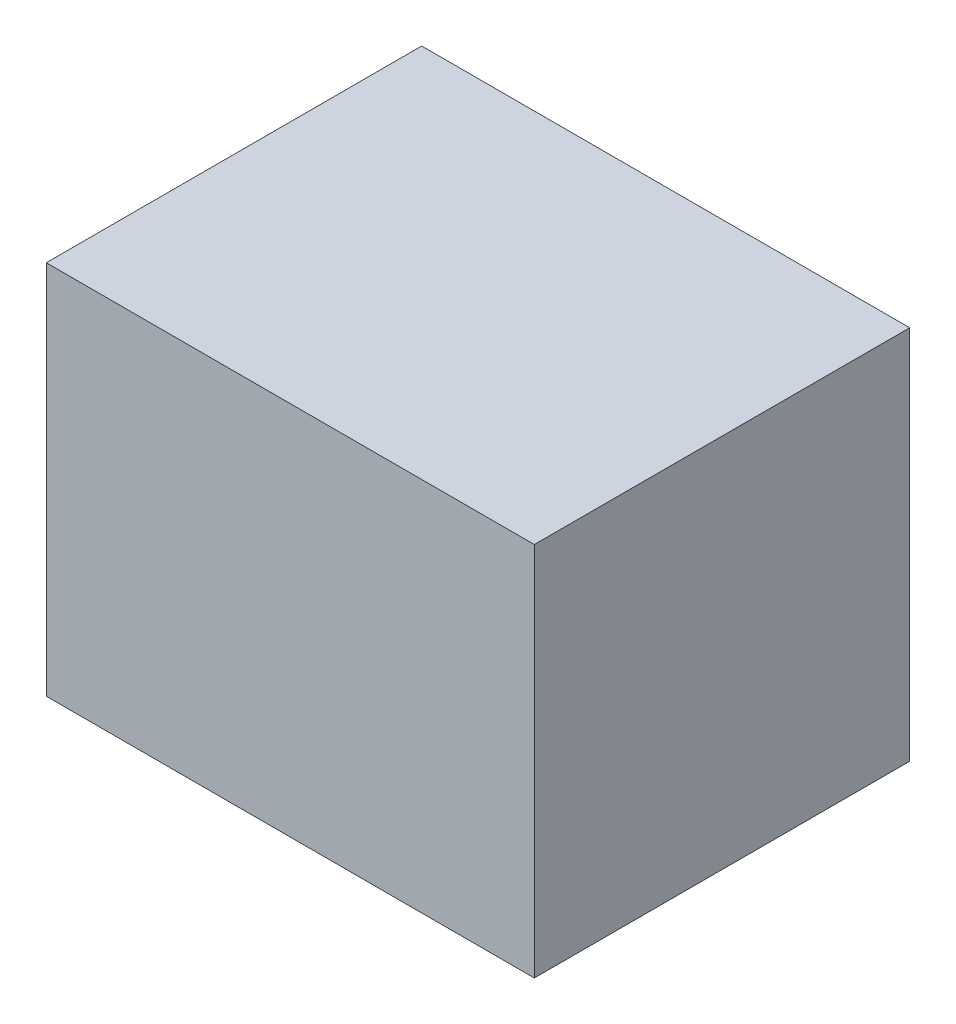
from build123d import *

# Parameters (mm, degrees)
SKETCH1_W           = 650
SKETCH1_H           = 500
BOSS_EXTRUDE1_DEPTH = 500


with BuildPart() as part:
    # Sketch1 → Boss-Extrude1 (new body)
    with BuildSketch(Plane(origin=(0, 0, 0), x_dir=(1, 0, 0), z_dir=(0, 1, 0))):
        Rectangle(SKETCH1_W, SKETCH1_H)
    extrude(amount=BOSS_EXTRUDE1_DEPTH)


solid = part.part
